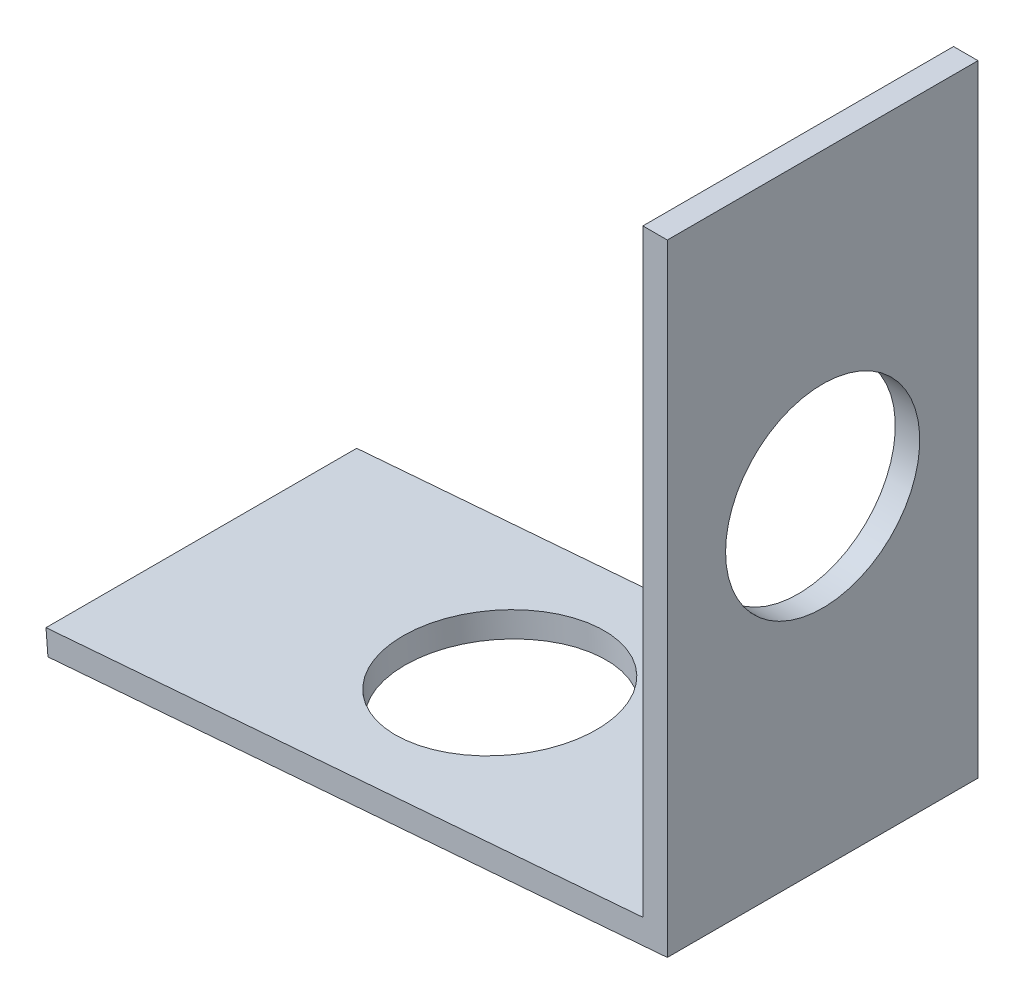
from build123d import *

# Parameters (mm, degrees)
BOSS_EXTRUDE1_DEPTH            = 6.35
F_5_16_0_3125_DIAMETER_HOLE1_D = 7.9375
F_5_16_0_3125_DIAMETER_HOLE2_D = 7.9375


with BuildPart() as part:
    # Sketch1 → Boss-Extrude1 (new body, symmetric)
    with BuildSketch(Plane.XY):
        Polygon((0, 0), (0, 25.4), (-1, 25.4), (-1, 0.923419949), (-25.399102496, -1.022542132), (-25.319599474, -2.019376756), align=None)
    extrude(amount=BOSS_EXTRUDE1_DEPTH, both=True)

    # 5/16 (0.3125) Diameter Hole1 (through all)
    with Locations(Plane(origin=(-1, 13.161709974, 0), x_dir=(0, -1, 0), z_dir=(-1, 0, 0))):
        with Locations((0, 0)):
            Hole(F_5_16_0_3125_DIAMETER_HOLE1_D / 2)

    # 5/16 (0.3125) Diameter Hole2 (through all)
    with Locations(Plane(origin=(-13.199551248, -0.049561091, 0), x_dir=(0.996834625, 0.079503022, 0), z_dir=(-0.079503022, 0.996834625, 0))):
        with Locations((0, 0)):
            Hole(F_5_16_0_3125_DIAMETER_HOLE2_D / 2)


solid = part.part
